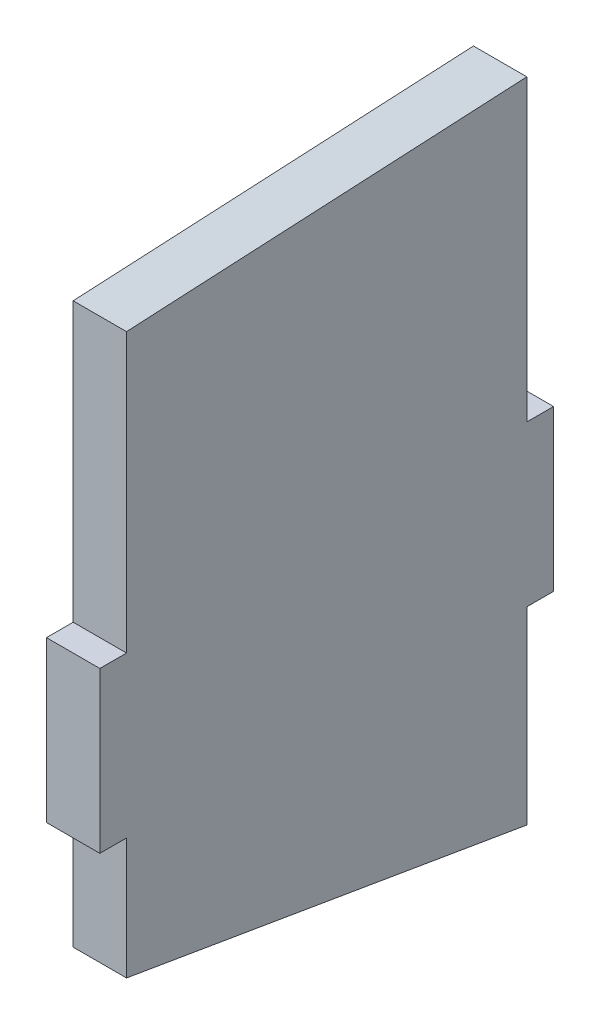
from build123d import *

# Parameters (mm, degrees)
SKETCH1_W           = 12.7
SKETCH1_H           = 76.2
SKETCH1_W_2         = 190.5
BOSS_EXTRUDE1_DEPTH = 25.4


with BuildPart() as part:
    # Sketch1 → Boss-Extrude1 (new body)
    with BuildSketch(Plane(origin=(0, 0, 0), x_dir=(0, 0, -1), z_dir=(1, 0, 0))):
        Polygon((95.25, 180.323740444), (-95.25, 170.563269744), (-95.25, 38.1), (95.25, 38.1), align=None)
        with Locations((101.6, 0)):
            Rectangle(SKETCH1_W, SKETCH1_H)
        Rectangle(SKETCH1_W_2, SKETCH1_H)
        with Locations((-101.6, 0)):
            Rectangle(SKETCH1_W, SKETCH1_H)
        Polygon((95.25, -38.1), (-95.25, -38.1), (-95.25, -95.823816988), (95.25, -128.029563346), align=None)
    extrude(amount=BOSS_EXTRUDE1_DEPTH)


solid = part.part
